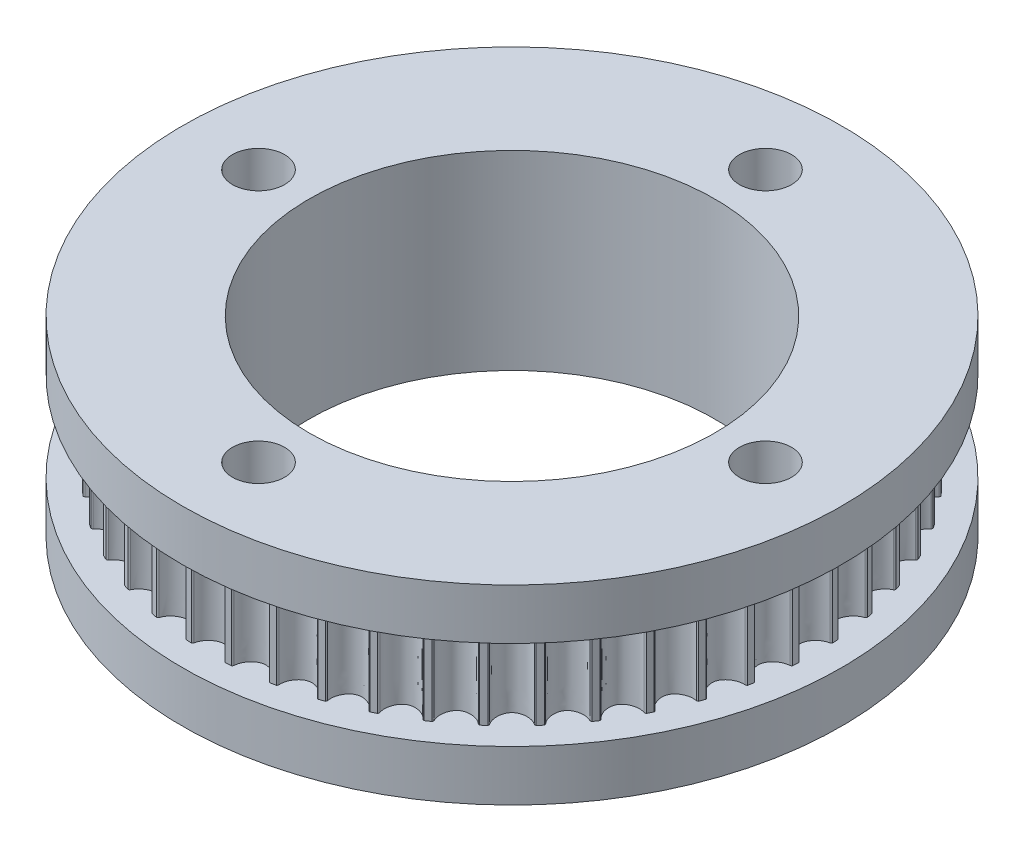
from build123d import *

# Parameters (mm, degrees)
BOSS_EXTRUDE1_DEPTH = 11.176
SKETCH2_R           = 41.275
BOSS_EXTRUDE2_DEPTH = 6.35
SKETCH4_R           = 41.275
BOSS_EXTRUDE3_DEPTH = 6.35
SKETCH5_R           = 25.4
SKETCH5_R_2         = 3.2639
CUT_EXTRUDE1_DEPTH  = 24.876


with BuildPart() as part:
    # Sketch1 → Boss-Extrude1 (new body)
    with BuildSketch(Plane(origin=(0, 0, 0), x_dir=(1, 0, 0), z_dir=(0, 1, 0))):
        with BuildLine():
            ThreePointArc((37.875301119, 1.97727387), (37.968782266, 2.037632371), (38.040837379, 2.122425851))
            ThreePointArc((38.040837379, 2.122425851), (38.018424975, 2.491859224), (37.992424907, 2.861057448))
            ThreePointArc((37.992424907, 2.861057448), (37.909918465, 2.935720429), (37.809358697, 2.983360816))
            add(Edge.make_bspline(
                [(37.293186638, 6.904076853), (36.808240215, 6.763005976), (35.985587822, 6.076875328), (35.580235057, 4.68422681), (36.332219721, 3.443944655), (37.304424592, 2.994111449), (37.809358697, 2.983360816)],
                knots=[0.030184697, 0.030184697, 0.030184697, 0.030184697, 0.291618348, 0.5, 0.708381652, 0.969815303, 0.969815303, 0.969815303, 0.969815303], degree=3))
            ThreePointArc((37.293186638, 6.904076853), (37.377989676, 6.976120716), (37.438360577, 7.069593856))
            ThreePointArc((37.438360577, 7.069593856), (37.367919183, 7.432941269), (37.29395151, 7.795587262))
            ThreePointArc((37.29395151, 7.795587262), (37.202405448, 7.858842238), (37.096487664, 7.892949372))
            add(Edge.make_bspline(
                [(36.072975394, 11.712749166), (35.610591199, 11.50958696), (34.884534732, 10.721948571), (34.664426925, 9.288305201), (35.571867563, 8.156787526), (36.594470102, 7.837700905), (37.096487664, 7.892949372)],
                knots=[0.030184697, 0.030184697, 0.030184697, 0.030184697, 0.291618348, 0.5, 0.708381652, 0.969815303, 0.969815303, 0.969815303, 0.969815303], degree=3))
            ThreePointArc((36.072975394, 11.712749166), (36.147649319, 11.795245702), (36.195303046, 11.895799149))
            ThreePointArc((36.195303046, 11.895799149), (36.078037934, 12.246843628), (35.957368264, 12.596732415))
            ThreePointArc((35.957368264, 12.596732415), (35.85834896, 12.647497078), (35.748885443, 12.667487375))
            add(Edge.make_bspline(
                [(34.23554554, 16.321013093), (33.803635095, 16.05923572), (33.186597581, 15.1835663), (33.155500837, 13.733458114), (34.202870888, 12.730065501), (35.258374082, 12.547185126), (35.748885443, 12.667487375)],
                knots=[0.030184697, 0.030184697, 0.030184697, 0.030184697, 0.291618348, 0.5, 0.708381652, 0.969815303, 0.969815303, 0.969815303, 0.969815303], degree=3))
            ThreePointArc((34.23554554, 16.321013093), (34.29881266, 16.412550763), (34.332933845, 16.518464021))
            ThreePointArc((34.332933845, 16.518464021), (34.170851452, 16.851199097), (34.005544477, 17.182343985))
            ThreePointArc((34.005544477, 17.182343985), (33.900746179, 17.219749736), (33.78960988, 17.225281158))
            add(Edge.make_bspline(
                [(31.81233601, 20.650019961), (31.418289422, 20.334106504), (30.920828545, 19.385389001), (31.079274937, 17.943627751), (32.248653609, 17.085528526), (33.318997507, 17.041983531), (33.78960988, 17.225281158)],
                knots=[0.030184697, 0.030184697, 0.030184697, 0.030184697, 0.291618348, 0.5, 0.708381652, 0.969815303, 0.969815303, 0.969815303, 0.969815303], degree=3))
            ThreePointArc((31.81233601, 20.650019961), (31.863113808, 20.74903253), (31.883118626, 20.858493394))
            ThreePointArc((31.883118626, 20.858493394), (31.678992229, 21.167225878), (31.471876396, 21.473960885))
            ThreePointArc((31.471876396, 21.473960885), (31.363092232, 21.497367702), (31.252184724, 21.488345604))
            add(Edge.make_bspline(
                [(28.84480859, 24.625699263), (28.495368107, 24.261055088), (28.12599556, 23.255522321), (28.471274027, 21.846776943), (29.742652927, 21.148653421), (30.809523646, 21.245188873), (31.252184724, 21.488345604)],
                knots=[0.030184697, 0.030184697, 0.030184697, 0.030184697, 0.291618348, 0.5, 0.708381652, 0.969815303, 0.969815303, 0.969815303, 0.969815303], degree=3))
            ThreePointArc((28.84480859, 24.625699263), (28.882228243, 24.730492598), (28.887774408, 24.841628162))
            ThreePointArc((28.887774408, 24.841628162), (28.645096665, 25.121075555), (28.399715785, 25.398152361))
            ThreePointArc((28.399715785, 25.398152361), (28.288807081, 25.407159746), (28.180026023, 25.383738499))
            add(Edge.make_bspline(
                [(25.383738499, 28.180026023), (25.084883142, 27.772890294), (24.849918992, 26.727747206), (25.376121724, 25.376121724), (26.727747206, 24.849918992), (27.772890294, 25.084883142), (28.180026023, 25.383738499)],
                knots=[0.030184697, 0.030184697, 0.030184697, 0.030184697, 0.291618348, 0.5, 0.708381652, 0.969815303, 0.969815303, 0.969815303, 0.969815303], degree=3))
            ThreePointArc((25.383738499, 28.180026023), (25.407159746, 28.288807081), (25.398152361, 28.399715785))
            ThreePointArc((25.398152361, 28.399715785), (25.121075555, 28.645096665), (24.841628162, 28.887774408))
            ThreePointArc((24.841628162, 28.887774408), (24.730492598, 28.882228243), (24.625699263, 28.84480859))
            add(Edge.make_bspline(
                [(21.488345604, 31.252184724), (21.245188873, 30.809523646), (21.148653421, 29.742652927), (21.846776943, 28.471274027), (23.255522321, 28.12599556), (24.261055088, 28.495368107), (24.625699263, 28.84480859)],
                knots=[0.030184697, 0.030184697, 0.030184697, 0.030184697, 0.291618348, 0.5, 0.708381652, 0.969815303, 0.969815303, 0.969815303, 0.969815303], degree=3))
            ThreePointArc((21.488345604, 31.252184724), (21.497367702, 31.363092232), (21.473960885, 31.471876396))
            ThreePointArc((21.473960885, 31.471876396), (21.167225878, 31.678992229), (20.858493394, 31.883118626))
            ThreePointArc((20.858493394, 31.883118626), (20.74903253, 31.863113808), (20.650019961, 31.81233601))
            add(Edge.make_bspline(
                [(17.225281158, 33.78960988), (17.041983531, 33.318997507), (17.085528526, 32.248653609), (17.943627751, 31.079274937), (19.385389001, 30.920828545), (20.334106504, 31.418289422), (20.650019961, 31.81233601)],
                knots=[0.030184697, 0.030184697, 0.030184697, 0.030184697, 0.291618348, 0.5, 0.708381652, 0.969815303, 0.969815303, 0.969815303, 0.969815303], degree=3))
            ThreePointArc((17.225281158, 33.78960988), (17.219749736, 33.900746179), (17.182343985, 34.005544477))
            ThreePointArc((17.182343985, 34.005544477), (16.851199097, 34.170851452), (16.518464021, 34.332933845))
            ThreePointArc((16.518464021, 34.332933845), (16.412550763, 34.29881266), (16.321013093, 34.23554554))
            add(Edge.make_bspline(
                [(12.667487375, 35.748885443), (12.547185126, 35.258374082), (12.730065501, 34.202870888), (13.733458114, 33.155500837), (15.1835663, 33.186597581), (16.059235719, 33.803635095), (16.321013093, 34.23554554)],
                knots=[0.030184697, 0.030184697, 0.030184697, 0.030184697, 0.291618348, 0.5, 0.708381652, 0.969815303, 0.969815303, 0.969815303, 0.969815303], degree=3))
            ThreePointArc((12.667487375, 35.748885443), (12.647497078, 35.85834896), (12.596732415, 35.957368264))
            ThreePointArc((12.596732415, 35.957368264), (12.246843628, 36.078037934), (11.895799149, 36.195303046))
            ThreePointArc((11.895799149, 36.195303046), (11.795245702, 36.147649319), (11.712749166, 36.072975394))
            add(Edge.make_bspline(
                [(7.892949372, 37.096487664), (7.837700905, 36.594470102), (8.156787526, 35.571867563), (9.288305201, 34.664426925), (10.721948571, 34.884534732), (11.50958696, 35.610591199), (11.712749166, 36.072975394)],
                knots=[0.030184697, 0.030184697, 0.030184697, 0.030184697, 0.291618348, 0.5, 0.708381652, 0.969815303, 0.969815303, 0.969815303, 0.969815303], degree=3))
            ThreePointArc((7.892949372, 37.096487664), (7.858842238, 37.202405448), (7.795587262, 37.29395151))
            ThreePointArc((7.795587262, 37.29395151), (7.432941269, 37.367919183), (7.069593856, 37.438360577))
            ThreePointArc((7.069593856, 37.438360577), (6.976120716, 37.377989676), (6.904076852, 37.293186638))
            add(Edge.make_bspline(
                [(2.983360816, 37.809358697), (2.994111449, 37.304424592), (3.443944655, 36.332219721), (4.68422681, 35.580235057), (6.076875328, 35.985587822), (6.763005976, 36.808240215), (6.904076852, 37.293186638)],
                knots=[0.030184697, 0.030184697, 0.030184697, 0.030184697, 0.291618348, 0.5, 0.708381652, 0.969815303, 0.969815303, 0.969815303, 0.969815303], degree=3))
            ThreePointArc((2.983360816, 37.809358697), (2.935720429, 37.909918465), (2.861057448, 37.992424907))
            ThreePointArc((2.861057448, 37.992424907), (2.491859224, 38.018424975), (2.122425851, 38.040837379))
            ThreePointArc((2.122425851, 38.040837379), (2.037632371, 37.968782266), (1.97727387, 37.875301119))
            add(Edge.make_bspline(
                [(-1.97727387, 37.875301119), (-1.900708085, 37.376090035), (-1.327825064, 36.470917526), (0, 35.887255503), (1.327825064, 36.470917526), (1.900708085, 37.376090035), (1.97727387, 37.875301119)],
                knots=[0.030184697, 0.030184697, 0.030184697, 0.030184697, 0.291618348, 0.5, 0.708381652, 0.969815303, 0.969815303, 0.969815303, 0.969815303], degree=3))
            ThreePointArc((-1.97727387, 37.875301119), (-2.037632371, 37.968782266), (-2.122425851, 38.040837379))
            ThreePointArc((-2.122425851, 38.040837379), (-2.491859224, 38.018424975), (-2.861057448, 37.992424907))
            ThreePointArc((-2.861057448, 37.992424907), (-2.935720429, 37.909918465), (-2.983360816, 37.809358697))
            add(Edge.make_bspline(
                [(-6.904076852, 37.293186638), (-6.763005976, 36.808240215), (-6.076875328, 35.985587822), (-4.68422681, 35.580235057), (-3.443944655, 36.332219721), (-2.994111449, 37.304424592), (-2.983360816, 37.809358697)],
                knots=[0.030184697, 0.030184697, 0.030184697, 0.030184697, 0.291618348, 0.5, 0.708381652, 0.969815303, 0.969815303, 0.969815303, 0.969815303], degree=3))
            ThreePointArc((-6.904076852, 37.293186638), (-6.976120716, 37.377989676), (-7.069593856, 37.438360577))
            ThreePointArc((-7.069593856, 37.438360577), (-7.432941269, 37.367919183), (-7.795587262, 37.29395151))
            ThreePointArc((-7.795587262, 37.29395151), (-7.858842238, 37.202405448), (-7.892949372, 37.096487664))
            add(Edge.make_bspline(
                [(-11.712749166, 36.072975394), (-11.50958696, 35.610591199), (-10.721948571, 34.884534732), (-9.288305201, 34.664426925), (-8.156787526, 35.571867563), (-7.837700905, 36.594470102), (-7.892949372, 37.096487664)],
                knots=[0.030184697, 0.030184697, 0.030184697, 0.030184697, 0.291618348, 0.5, 0.708381652, 0.969815303, 0.969815303, 0.969815303, 0.969815303], degree=3))
            ThreePointArc((-11.712749166, 36.072975394), (-11.795245702, 36.147649319), (-11.895799149, 36.195303046))
            ThreePointArc((-11.895799149, 36.195303046), (-12.246843628, 36.078037934), (-12.596732415, 35.957368264))
            ThreePointArc((-12.596732415, 35.957368264), (-12.647497078, 35.85834896), (-12.667487375, 35.748885443))
            add(Edge.make_bspline(
                [(-16.321013093, 34.23554554), (-16.059235719, 33.803635095), (-15.1835663, 33.186597581), (-13.733458114, 33.155500837), (-12.730065501, 34.202870888), (-12.547185126, 35.258374082), (-12.667487375, 35.748885443)],
                knots=[0.030184697, 0.030184697, 0.030184697, 0.030184697, 0.291618348, 0.5, 0.708381652, 0.969815303, 0.969815303, 0.969815303, 0.969815303], degree=3))
            ThreePointArc((-16.321013093, 34.23554554), (-16.412550763, 34.29881266), (-16.518464021, 34.332933845))
            ThreePointArc((-16.518464021, 34.332933845), (-16.851199097, 34.170851452), (-17.182343985, 34.005544477))
            ThreePointArc((-17.182343985, 34.005544477), (-17.219749736, 33.900746179), (-17.225281158, 33.78960988))
            add(Edge.make_bspline(
                [(-20.650019961, 31.81233601), (-20.334106504, 31.418289422), (-19.385389001, 30.920828545), (-17.943627751, 31.079274937), (-17.085528526, 32.248653609), (-17.041983531, 33.318997507), (-17.225281158, 33.78960988)],
                knots=[0.030184697, 0.030184697, 0.030184697, 0.030184697, 0.291618348, 0.5, 0.708381652, 0.969815303, 0.969815303, 0.969815303, 0.969815303], degree=3))
            ThreePointArc((-20.650019961, 31.81233601), (-20.74903253, 31.863113808), (-20.858493394, 31.883118626))
            ThreePointArc((-20.858493394, 31.883118626), (-21.167225878, 31.678992229), (-21.473960885, 31.471876396))
            ThreePointArc((-21.473960885, 31.471876396), (-21.497367702, 31.363092232), (-21.488345604, 31.252184724))
            add(Edge.make_bspline(
                [(-24.625699263, 28.84480859), (-24.261055088, 28.495368107), (-23.255522321, 28.12599556), (-21.846776943, 28.471274027), (-21.148653421, 29.742652927), (-21.245188873, 30.809523646), (-21.488345604, 31.252184724)],
                knots=[0.030184697, 0.030184697, 0.030184697, 0.030184697, 0.291618348, 0.5, 0.708381652, 0.969815303, 0.969815303, 0.969815303, 0.969815303], degree=3))
            ThreePointArc((-24.625699263, 28.84480859), (-24.730492598, 28.882228243), (-24.841628162, 28.887774408))
            ThreePointArc((-24.841628162, 28.887774408), (-25.121075555, 28.645096665), (-25.398152361, 28.399715785))
            ThreePointArc((-25.398152361, 28.399715785), (-25.407159746, 28.288807081), (-25.383738499, 28.180026023))
            add(Edge.make_bspline(
                [(-28.180026023, 25.383738499), (-27.772890294, 25.084883142), (-26.727747206, 24.849918992), (-25.376121724, 25.376121724), (-24.849918992, 26.727747206), (-25.084883142, 27.772890293), (-25.383738499, 28.180026023)],
                knots=[0.030184697, 0.030184697, 0.030184697, 0.030184697, 0.291618348, 0.5, 0.708381652, 0.969815303, 0.969815303, 0.969815303, 0.969815303], degree=3))
            ThreePointArc((-28.180026023, 25.383738499), (-28.288807081, 25.407159746), (-28.399715785, 25.398152361))
            ThreePointArc((-28.399715785, 25.398152361), (-28.645096665, 25.121075555), (-28.887774408, 24.841628162))
            ThreePointArc((-28.887774408, 24.841628162), (-28.882228243, 24.730492598), (-28.84480859, 24.625699263))
            add(Edge.make_bspline(
                [(-31.252184724, 21.488345604), (-30.809523646, 21.245188873), (-29.742652927, 21.148653421), (-28.471274027, 21.846776943), (-28.12599556, 23.255522321), (-28.495368107, 24.261055088), (-28.84480859, 24.625699263)],
                knots=[0.030184697, 0.030184697, 0.030184697, 0.030184697, 0.291618348, 0.5, 0.708381652, 0.969815303, 0.969815303, 0.969815303, 0.969815303], degree=3))
            ThreePointArc((-31.252184724, 21.488345604), (-31.363092232, 21.497367702), (-31.471876396, 21.473960885))
            ThreePointArc((-31.471876396, 21.473960885), (-31.678992229, 21.167225878), (-31.883118626, 20.858493394))
            ThreePointArc((-31.883118626, 20.858493394), (-31.863113808, 20.74903253), (-31.81233601, 20.650019961))
            add(Edge.make_bspline(
                [(-33.78960988, 17.225281158), (-33.318997507, 17.041983531), (-32.248653609, 17.085528526), (-31.079274937, 17.943627751), (-30.920828545, 19.385389001), (-31.418289422, 20.334106504), (-31.81233601, 20.650019961)],
                knots=[0.030184697, 0.030184697, 0.030184697, 0.030184697, 0.291618348, 0.5, 0.708381652, 0.969815303, 0.969815303, 0.969815303, 0.969815303], degree=3))
            ThreePointArc((-33.78960988, 17.225281158), (-33.900746179, 17.219749736), (-34.005544477, 17.182343985))
            ThreePointArc((-34.005544477, 17.182343985), (-34.170851452, 16.851199097), (-34.332933845, 16.518464021))
            ThreePointArc((-34.332933845, 16.518464021), (-34.29881266, 16.412550763), (-34.23554554, 16.321013093))
            add(Edge.make_bspline(
                [(-35.748885443, 12.667487375), (-35.258374082, 12.547185126), (-34.202870888, 12.730065501), (-33.155500837, 13.733458114), (-33.186597581, 15.1835663), (-33.803635095, 16.059235719), (-34.23554554, 16.321013093)],
                knots=[0.030184697, 0.030184697, 0.030184697, 0.030184697, 0.291618348, 0.5, 0.708381652, 0.969815303, 0.969815303, 0.969815303, 0.969815303], degree=3))
            ThreePointArc((-35.748885443, 12.667487375), (-35.85834896, 12.647497078), (-35.957368264, 12.596732415))
            ThreePointArc((-35.957368264, 12.596732415), (-36.078037934, 12.246843628), (-36.195303046, 11.895799149))
            ThreePointArc((-36.195303046, 11.895799149), (-36.147649319, 11.795245702), (-36.072975394, 11.712749166))
            add(Edge.make_bspline(
                [(-37.096487664, 7.892949372), (-36.594470102, 7.837700905), (-35.571867563, 8.156787526), (-34.664426925, 9.288305201), (-34.884534732, 10.721948571), (-35.610591199, 11.50958696), (-36.072975394, 11.712749166)],
                knots=[0.030184697, 0.030184697, 0.030184697, 0.030184697, 0.291618348, 0.5, 0.708381652, 0.969815303, 0.969815303, 0.969815303, 0.969815303], degree=3))
            ThreePointArc((-37.096487664, 7.892949372), (-37.202405448, 7.858842238), (-37.29395151, 7.795587262))
            ThreePointArc((-37.29395151, 7.795587262), (-37.367919183, 7.432941269), (-37.438360577, 7.069593855))
            ThreePointArc((-37.438360577, 7.069593855), (-37.377989676, 6.976120716), (-37.293186638, 6.904076852))
            add(Edge.make_bspline(
                [(-37.809358697, 2.983360816), (-37.304424592, 2.994111449), (-36.332219721, 3.443944655), (-35.580235057, 4.68422681), (-35.985587822, 6.076875328), (-36.808240215, 6.763005976), (-37.293186638, 6.904076852)],
                knots=[0.030184697, 0.030184697, 0.030184697, 0.030184697, 0.291618348, 0.5, 0.708381652, 0.969815303, 0.969815303, 0.969815303, 0.969815303], degree=3))
            ThreePointArc((-37.809358697, 2.983360816), (-37.909918465, 2.935720429), (-37.992424906, 2.861057448))
            ThreePointArc((-37.992424907, 2.861057448), (-38.018424975, 2.491859224), (-38.040837379, 2.122425851))
            ThreePointArc((-38.040837379, 2.122425851), (-37.968782266, 2.037632371), (-37.875301119, 1.97727387))
            add(Edge.make_bspline(
                [(-37.875301119, -1.97727387), (-37.376090035, -1.900708085), (-36.470917527, -1.327825064), (-35.887255503, 0), (-36.470917527, 1.327825064), (-37.376090035, 1.900708084), (-37.875301119, 1.97727387)],
                knots=[0.030184697, 0.030184697, 0.030184697, 0.030184697, 0.291618348, 0.5, 0.708381652, 0.969815303, 0.969815303, 0.969815303, 0.969815303], degree=3))
            ThreePointArc((-37.875301119, -1.97727387), (-37.968782266, -2.037632371), (-38.040837379, -2.122425851))
            ThreePointArc((-38.040837379, -2.122425851), (-38.018424975, -2.491859224), (-37.992424907, -2.861057448))
            ThreePointArc((-37.992424906, -2.861057448), (-37.909918465, -2.935720429), (-37.809358697, -2.983360816))
            add(Edge.make_bspline(
                [(-37.293186638, -6.904076853), (-36.808240215, -6.763005976), (-35.985587822, -6.076875328), (-35.580235057, -4.68422681), (-36.332219721, -3.443944655), (-37.304424592, -2.994111449), (-37.809358697, -2.983360816)],
                knots=[0.030184697, 0.030184697, 0.030184697, 0.030184697, 0.291618348, 0.5, 0.708381652, 0.969815303, 0.969815303, 0.969815303, 0.969815303], degree=3))
            ThreePointArc((-37.293186638, -6.904076853), (-37.377989676, -6.976120716), (-37.438360577, -7.069593856))
            ThreePointArc((-37.438360577, -7.069593856), (-37.367919183, -7.432941269), (-37.29395151, -7.795587262))
            ThreePointArc((-37.29395151, -7.795587262), (-37.202405448, -7.858842238), (-37.096487664, -7.892949372))
            add(Edge.make_bspline(
                [(-36.072975394, -11.712749166), (-35.610591199, -11.50958696), (-34.884534732, -10.721948571), (-34.664426925, -9.288305201), (-35.571867563, -8.156787526), (-36.594470102, -7.837700905), (-37.096487664, -7.892949372)],
                knots=[0.030184697, 0.030184697, 0.030184697, 0.030184697, 0.291618348, 0.5, 0.708381652, 0.969815303, 0.969815303, 0.969815303, 0.969815303], degree=3))
            ThreePointArc((-36.072975394, -11.712749166), (-36.147649319, -11.795245702), (-36.195303046, -11.895799149))
            ThreePointArc((-36.195303046, -11.895799149), (-36.078037934, -12.246843628), (-35.957368264, -12.596732415))
            ThreePointArc((-35.957368264, -12.596732415), (-35.85834896, -12.647497078), (-35.748885443, -12.667487375))
            add(Edge.make_bspline(
                [(-34.23554554, -16.321013093), (-33.803635095, -16.05923572), (-33.186597581, -15.1835663), (-33.155500837, -13.733458114), (-34.202870888, -12.730065501), (-35.258374082, -12.547185126), (-35.748885443, -12.667487375)],
                knots=[0.030184697, 0.030184697, 0.030184697, 0.030184697, 0.291618348, 0.5, 0.708381652, 0.969815303, 0.969815303, 0.969815303, 0.969815303], degree=3))
            ThreePointArc((-34.23554554, -16.321013093), (-34.29881266, -16.412550763), (-34.332933845, -16.518464021))
            ThreePointArc((-34.332933845, -16.518464021), (-34.170851452, -16.851199097), (-34.005544477, -17.182343985))
            ThreePointArc((-34.005544477, -17.182343985), (-33.900746179, -17.219749736), (-33.78960988, -17.225281158))
            add(Edge.make_bspline(
                [(-31.81233601, -20.650019961), (-31.418289422, -20.334106504), (-30.920828545, -19.385389001), (-31.079274937, -17.943627751), (-32.248653609, -17.085528526), (-33.318997507, -17.041983531), (-33.78960988, -17.225281158)],
                knots=[0.030184697, 0.030184697, 0.030184697, 0.030184697, 0.291618348, 0.5, 0.708381652, 0.969815303, 0.969815303, 0.969815303, 0.969815303], degree=3))
            ThreePointArc((-31.81233601, -20.650019961), (-31.863113808, -20.74903253), (-31.883118626, -20.858493394))
            ThreePointArc((-31.883118626, -20.858493394), (-31.678992229, -21.167225878), (-31.471876396, -21.473960885))
            ThreePointArc((-31.471876396, -21.473960885), (-31.363092232, -21.497367702), (-31.252184724, -21.488345604))
            add(Edge.make_bspline(
                [(-28.84480859, -24.625699263), (-28.495368107, -24.261055088), (-28.12599556, -23.255522321), (-28.471274027, -21.846776943), (-29.742652927, -21.148653421), (-30.809523646, -21.245188873), (-31.252184724, -21.488345604)],
                knots=[0.030184697, 0.030184697, 0.030184697, 0.030184697, 0.291618348, 0.5, 0.708381652, 0.969815303, 0.969815303, 0.969815303, 0.969815303], degree=3))
            ThreePointArc((-28.84480859, -24.625699263), (-28.882228243, -24.730492598), (-28.887774408, -24.841628162))
            ThreePointArc((-28.887774408, -24.841628162), (-28.645096665, -25.121075555), (-28.399715785, -25.398152361))
            ThreePointArc((-28.399715785, -25.398152361), (-28.288807081, -25.407159746), (-28.180026023, -25.383738499))
            add(Edge.make_bspline(
                [(-25.383738499, -28.180026023), (-25.084883142, -27.772890294), (-24.849918992, -26.727747206), (-25.376121724, -25.376121724), (-26.727747206, -24.849918992), (-27.772890293, -25.084883142), (-28.180026023, -25.383738499)],
                knots=[0.030184697, 0.030184697, 0.030184697, 0.030184697, 0.291618348, 0.5, 0.708381652, 0.969815303, 0.969815303, 0.969815303, 0.969815303], degree=3))
            ThreePointArc((-25.383738499, -28.180026023), (-25.407159746, -28.288807081), (-25.398152361, -28.399715785))
            ThreePointArc((-25.398152361, -28.399715785), (-25.121075555, -28.645096665), (-24.841628162, -28.887774408))
            ThreePointArc((-24.841628162, -28.887774408), (-24.730492598, -28.882228243), (-24.625699263, -28.84480859))
            add(Edge.make_bspline(
                [(-21.488345604, -31.252184724), (-21.245188873, -30.809523646), (-21.148653421, -29.742652927), (-21.846776943, -28.471274027), (-23.255522321, -28.12599556), (-24.261055088, -28.495368107), (-24.625699263, -28.84480859)],
                knots=[0.030184697, 0.030184697, 0.030184697, 0.030184697, 0.291618348, 0.5, 0.708381652, 0.969815303, 0.969815303, 0.969815303, 0.969815303], degree=3))
            ThreePointArc((-21.488345604, -31.252184724), (-21.497367702, -31.363092232), (-21.473960885, -31.471876396))
            ThreePointArc((-21.473960885, -31.471876396), (-21.167225878, -31.678992229), (-20.858493394, -31.883118626))
            ThreePointArc((-20.858493394, -31.883118626), (-20.74903253, -31.863113808), (-20.650019961, -31.81233601))
            add(Edge.make_bspline(
                [(-17.225281157, -33.78960988), (-17.041983531, -33.318997507), (-17.085528526, -32.248653609), (-17.943627751, -31.079274937), (-19.385389001, -30.920828545), (-20.334106504, -31.418289422), (-20.650019961, -31.81233601)],
                knots=[0.030184697, 0.030184697, 0.030184697, 0.030184697, 0.291618348, 0.5, 0.708381652, 0.969815303, 0.969815303, 0.969815303, 0.969815303], degree=3))
            ThreePointArc((-17.225281157, -33.78960988), (-17.219749736, -33.900746179), (-17.182343985, -34.005544477))
            ThreePointArc((-17.182343985, -34.005544477), (-16.851199097, -34.170851452), (-16.518464021, -34.332933845))
            ThreePointArc((-16.518464021, -34.332933845), (-16.412550763, -34.29881266), (-16.321013093, -34.23554554))
            add(Edge.make_bspline(
                [(-12.667487375, -35.748885443), (-12.547185126, -35.258374082), (-12.730065501, -34.202870888), (-13.733458114, -33.155500837), (-15.1835663, -33.186597581), (-16.059235719, -33.803635095), (-16.321013093, -34.23554554)],
                knots=[0.030184697, 0.030184697, 0.030184697, 0.030184697, 0.291618348, 0.5, 0.708381652, 0.969815303, 0.969815303, 0.969815303, 0.969815303], degree=3))
            ThreePointArc((-12.667487375, -35.748885443), (-12.647497078, -35.85834896), (-12.596732415, -35.957368264))
            ThreePointArc((-12.596732415, -35.957368264), (-12.246843628, -36.078037934), (-11.895799149, -36.195303046))
            ThreePointArc((-11.895799149, -36.195303046), (-11.795245702, -36.147649319), (-11.712749165, -36.072975394))
            add(Edge.make_bspline(
                [(-7.892949372, -37.096487664), (-7.837700905, -36.594470102), (-8.156787526, -35.571867563), (-9.288305201, -34.664426925), (-10.721948571, -34.884534732), (-11.50958696, -35.610591199), (-11.712749165, -36.072975394)],
                knots=[0.030184697, 0.030184697, 0.030184697, 0.030184697, 0.291618348, 0.5, 0.708381652, 0.969815303, 0.969815303, 0.969815303, 0.969815303], degree=3))
            ThreePointArc((-7.892949372, -37.096487664), (-7.858842238, -37.202405448), (-7.795587262, -37.29395151))
            ThreePointArc((-7.795587262, -37.29395151), (-7.432941269, -37.367919183), (-7.069593855, -37.438360577))
            ThreePointArc((-7.069593855, -37.438360577), (-6.976120716, -37.377989676), (-6.904076852, -37.293186638))
            add(Edge.make_bspline(
                [(-2.983360816, -37.809358697), (-2.994111449, -37.304424592), (-3.443944655, -36.332219721), (-4.68422681, -35.580235057), (-6.076875328, -35.985587822), (-6.763005976, -36.808240215), (-6.904076852, -37.293186638)],
                knots=[0.030184697, 0.030184697, 0.030184697, 0.030184697, 0.291618348, 0.5, 0.708381652, 0.969815303, 0.969815303, 0.969815303, 0.969815303], degree=3))
            ThreePointArc((-2.983360816, -37.809358697), (-2.935720429, -37.909918465), (-2.861057448, -37.992424907))
            ThreePointArc((-2.861057448, -37.992424907), (-2.491859224, -38.018424975), (-2.122425851, -38.040837379))
            ThreePointArc((-2.122425851, -38.040837379), (-2.037632371, -37.968782266), (-1.97727387, -37.875301119))
            add(Edge.make_bspline(
                [(1.97727387, -37.875301119), (1.900708085, -37.376090035), (1.327825064, -36.470917526), (0, -35.887255503), (-1.327825064, -36.470917526), (-1.900708084, -37.376090035), (-1.97727387, -37.875301119)],
                knots=[0.030184697, 0.030184697, 0.030184697, 0.030184697, 0.291618348, 0.5, 0.708381652, 0.969815303, 0.969815303, 0.969815303, 0.969815303], degree=3))
            ThreePointArc((1.97727387, -37.875301119), (2.037632371, -37.968782266), (2.122425851, -38.040837379))
            ThreePointArc((2.122425851, -38.040837379), (2.491859224, -38.018424975), (2.861057448, -37.992424907))
            ThreePointArc((2.861057448, -37.992424907), (2.935720429, -37.909918465), (2.983360816, -37.809358697))
            add(Edge.make_bspline(
                [(6.904076853, -37.293186638), (6.763005976, -36.808240215), (6.076875328, -35.985587822), (4.68422681, -35.580235057), (3.443944655, -36.332219721), (2.994111449, -37.304424592), (2.983360816, -37.809358697)],
                knots=[0.030184697, 0.030184697, 0.030184697, 0.030184697, 0.291618348, 0.5, 0.708381652, 0.969815303, 0.969815303, 0.969815303, 0.969815303], degree=3))
            ThreePointArc((6.904076853, -37.293186638), (6.976120716, -37.377989676), (7.069593856, -37.438360577))
            ThreePointArc((7.069593856, -37.438360577), (7.432941269, -37.367919183), (7.795587262, -37.29395151))
            ThreePointArc((7.795587262, -37.29395151), (7.858842238, -37.202405448), (7.892949372, -37.096487664))
            add(Edge.make_bspline(
                [(11.712749166, -36.072975394), (11.50958696, -35.610591199), (10.721948571, -34.884534732), (9.288305201, -34.664426925), (8.156787526, -35.571867563), (7.837700905, -36.594470102), (7.892949372, -37.096487664)],
                knots=[0.030184697, 0.030184697, 0.030184697, 0.030184697, 0.291618348, 0.5, 0.708381652, 0.969815303, 0.969815303, 0.969815303, 0.969815303], degree=3))
            ThreePointArc((11.712749166, -36.072975394), (11.795245702, -36.147649319), (11.895799149, -36.195303046))
            ThreePointArc((11.895799149, -36.195303046), (12.246843628, -36.078037934), (12.596732415, -35.957368264))
            ThreePointArc((12.596732415, -35.957368264), (12.647497078, -35.85834896), (12.667487375, -35.748885443))
            add(Edge.make_bspline(
                [(16.321013093, -34.23554554), (16.05923572, -33.803635095), (15.1835663, -33.186597581), (13.733458114, -33.155500837), (12.730065501, -34.202870888), (12.547185126, -35.258374082), (12.667487375, -35.748885443)],
                knots=[0.030184697, 0.030184697, 0.030184697, 0.030184697, 0.291618348, 0.5, 0.708381652, 0.969815303, 0.969815303, 0.969815303, 0.969815303], degree=3))
            ThreePointArc((16.321013093, -34.23554554), (16.412550763, -34.29881266), (16.518464021, -34.332933845))
            ThreePointArc((16.518464021, -34.332933845), (16.851199097, -34.170851452), (17.182343985, -34.005544477))
            ThreePointArc((17.182343985, -34.005544477), (17.219749736, -33.900746179), (17.225281158, -33.78960988))
            add(Edge.make_bspline(
                [(20.650019961, -31.81233601), (20.334106504, -31.418289422), (19.385389001, -30.920828545), (17.943627751, -31.079274937), (17.085528526, -32.248653609), (17.041983531, -33.318997507), (17.225281158, -33.78960988)],
                knots=[0.030184697, 0.030184697, 0.030184697, 0.030184697, 0.291618348, 0.5, 0.708381652, 0.969815303, 0.969815303, 0.969815303, 0.969815303], degree=3))
            ThreePointArc((20.650019961, -31.81233601), (20.74903253, -31.863113808), (20.858493394, -31.883118626))
            ThreePointArc((20.858493394, -31.883118626), (21.167225878, -31.678992229), (21.473960885, -31.471876396))
            ThreePointArc((21.473960885, -31.471876396), (21.497367702, -31.363092232), (21.488345604, -31.252184724))
            add(Edge.make_bspline(
                [(24.625699263, -28.84480859), (24.261055088, -28.495368107), (23.255522321, -28.12599556), (21.846776943, -28.471274027), (21.148653421, -29.742652927), (21.245188873, -30.809523646), (21.488345604, -31.252184724)],
                knots=[0.030184697, 0.030184697, 0.030184697, 0.030184697, 0.291618348, 0.5, 0.708381652, 0.969815303, 0.969815303, 0.969815303, 0.969815303], degree=3))
            ThreePointArc((24.625699263, -28.84480859), (24.730492598, -28.882228243), (24.841628162, -28.887774408))
            ThreePointArc((24.841628162, -28.887774408), (25.121075555, -28.645096665), (25.398152361, -28.399715785))
            ThreePointArc((25.398152361, -28.399715785), (25.407159747, -28.288807081), (25.383738499, -28.180026023))
            add(Edge.make_bspline(
                [(28.180026023, -25.383738499), (27.772890294, -25.084883142), (26.727747206, -24.849918992), (25.376121724, -25.376121724), (24.849918992, -26.727747206), (25.084883142, -27.772890293), (25.383738499, -28.180026023)],
                knots=[0.030184697, 0.030184697, 0.030184697, 0.030184697, 0.291618348, 0.5, 0.708381652, 0.969815303, 0.969815303, 0.969815303, 0.969815303], degree=3))
            ThreePointArc((28.180026023, -25.383738499), (28.288807081, -25.407159746), (28.399715785, -25.398152361))
            ThreePointArc((28.399715785, -25.398152361), (28.645096665, -25.121075555), (28.887774408, -24.841628162))
            ThreePointArc((28.887774408, -24.841628162), (28.882228244, -24.730492598), (28.84480859, -24.625699263))
            add(Edge.make_bspline(
                [(31.252184724, -21.488345604), (30.809523646, -21.245188873), (29.742652927, -21.148653421), (28.471274027, -21.846776943), (28.125995559, -23.255522321), (28.495368107, -24.261055088), (28.84480859, -24.625699263)],
                knots=[0.030184697, 0.030184697, 0.030184697, 0.030184697, 0.291618348, 0.5, 0.708381652, 0.969815303, 0.969815303, 0.969815303, 0.969815303], degree=3))
            ThreePointArc((31.252184724, -21.488345604), (31.363092232, -21.497367702), (31.471876396, -21.473960885))
            ThreePointArc((31.471876396, -21.473960885), (31.678992229, -21.167225878), (31.883118626, -20.858493394))
            ThreePointArc((31.883118626, -20.858493394), (31.863113808, -20.74903253), (31.81233601, -20.650019961))
            add(Edge.make_bspline(
                [(33.78960988, -17.225281158), (33.318997507, -17.041983531), (32.248653609, -17.085528526), (31.079274937, -17.943627751), (30.920828545, -19.385389001), (31.418289422, -20.334106504), (31.81233601, -20.650019961)],
                knots=[0.030184697, 0.030184697, 0.030184697, 0.030184697, 0.291618348, 0.5, 0.708381652, 0.969815303, 0.969815303, 0.969815303, 0.969815303], degree=3))
            ThreePointArc((33.78960988, -17.225281158), (33.900746179, -17.219749736), (34.005544477, -17.182343985))
            ThreePointArc((34.005544477, -17.182343985), (34.170851452, -16.851199097), (34.332933845, -16.518464021))
            ThreePointArc((34.332933845, -16.518464021), (34.29881266, -16.412550763), (34.23554554, -16.321013093))
            add(Edge.make_bspline(
                [(35.748885443, -12.667487375), (35.258374082, -12.547185126), (34.202870888, -12.730065501), (33.155500837, -13.733458114), (33.186597581, -15.1835663), (33.803635095, -16.059235719), (34.23554554, -16.321013093)],
                knots=[0.030184697, 0.030184697, 0.030184697, 0.030184697, 0.291618348, 0.5, 0.708381652, 0.969815303, 0.969815303, 0.969815303, 0.969815303], degree=3))
            ThreePointArc((35.748885443, -12.667487375), (35.85834896, -12.647497078), (35.957368264, -12.596732415))
            ThreePointArc((35.957368264, -12.596732415), (36.078037934, -12.246843628), (36.195303046, -11.895799149))
            ThreePointArc((36.195303046, -11.895799149), (36.147649319, -11.795245702), (36.072975394, -11.712749166))
            add(Edge.make_bspline(
                [(37.096487664, -7.892949372), (36.594470102, -7.837700905), (35.571867562, -8.156787526), (34.664426925, -9.288305201), (34.884534732, -10.721948571), (35.610591199, -11.50958696), (36.072975394, -11.712749166)],
                knots=[0.030184697, 0.030184697, 0.030184697, 0.030184697, 0.291618348, 0.5, 0.708381652, 0.969815303, 0.969815303, 0.969815303, 0.969815303], degree=3))
            ThreePointArc((37.096487664, -7.892949372), (37.202405448, -7.858842238), (37.29395151, -7.795587262))
            ThreePointArc((37.29395151, -7.795587262), (37.367919183, -7.432941269), (37.438360577, -7.069593855))
            ThreePointArc((37.438360577, -7.069593855), (37.377989676, -6.976120716), (37.293186638, -6.904076852))
            add(Edge.make_bspline(
                [(37.809358697, -2.983360816), (37.304424592, -2.994111449), (36.332219721, -3.443944655), (35.580235057, -4.68422681), (35.985587822, -6.076875328), (36.808240215, -6.763005976), (37.293186638, -6.904076852)],
                knots=[0.030184697, 0.030184697, 0.030184697, 0.030184697, 0.291618348, 0.5, 0.708381652, 0.969815303, 0.969815303, 0.969815303, 0.969815303], degree=3))
            ThreePointArc((37.809358697, -2.983360816), (37.909918465, -2.935720429), (37.992424907, -2.861057448))
            ThreePointArc((37.992424907, -2.861057448), (38.018424975, -2.491859224), (38.040837379, -2.122425851))
            ThreePointArc((38.040837379, -2.122425851), (37.968782266, -2.037632371), (37.875301119, -1.97727387))
            add(Edge.make_bspline(
                [(37.875301119, 1.97727387), (37.376090035, 1.900708085), (36.470917526, 1.327825064), (35.887255503, 0), (36.470917526, -1.327825064), (37.376090035, -1.900708084), (37.875301119, -1.97727387)],
                knots=[0.030184697, 0.030184697, 0.030184697, 0.030184697, 0.291618348, 0.5, 0.708381652, 0.969815303, 0.969815303, 0.969815303, 0.969815303], degree=3))
        make_face()
    extrude(amount=BOSS_EXTRUDE1_DEPTH)

    # Sketch2 → Boss-Extrude2 (add)
    with BuildSketch(Plane(origin=(0, 11.176, 0), x_dir=(1, 0, 0), z_dir=(0, 1, 0))):
        Circle(SKETCH2_R)
    extrude(amount=BOSS_EXTRUDE2_DEPTH)

    # Sketch4 → Boss-Extrude3 (add)
    with BuildSketch(Plane.XZ):
        Circle(SKETCH4_R)
    extrude(amount=BOSS_EXTRUDE3_DEPTH)

    # Sketch5 → Cut-Extrude1 (cut, through all)
    with BuildSketch(Plane(origin=(0, 17.526, 0), x_dir=(1, 0, 0), z_dir=(0, 1, 0))):
        Circle(SKETCH5_R)
        with Locations((0, 31.75)):
            Circle(SKETCH5_R_2)
        with Locations((31.75, 0)):
            Circle(SKETCH5_R_2)
        with Locations((0, -31.75)):
            Circle(SKETCH5_R_2)
        with Locations((-31.75, 0)):
            Circle(SKETCH5_R_2)
    extrude(amount=-CUT_EXTRUDE1_DEPTH, mode=Mode.SUBTRACT)


solid = part.part
